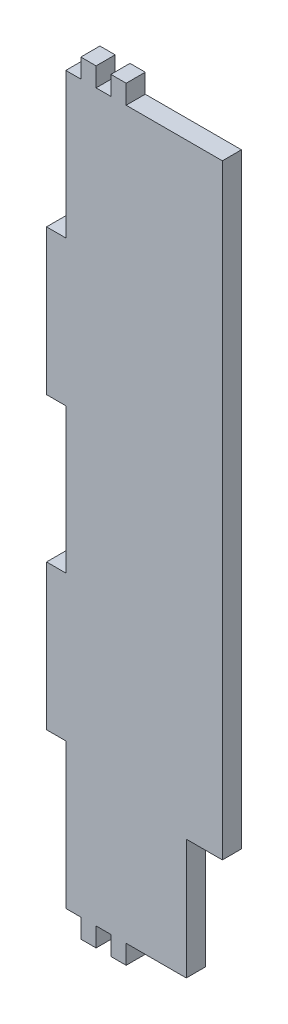
from build123d import *

# Parameters (mm, degrees)
SKETCH1_W           = 5
SKETCH1_H           = 6.35
SKETCH1_W_2         = 25
SKETCH1_H_2         = 241.325
SKETCH1_W_3         = 6.4
SKETCH1_H_3         = 48.265
SKETCH1_W_4         = 15
SKETCH1_W_5         = 12
SKETCH1_H_4         = 201.325
BOSS_EXTRUDE1_DEPTH = 6.35
BOSS_EXTRUDE2_DEPTH = 6.35


with BuildPart() as part:
    # Sketch1 → Boss-Extrude1 (new body)
    with BuildSketch(Plane.XY):
        with Locations((-5, 123.8375)):
            Rectangle(SKETCH1_W, SKETCH1_H)
        with Locations((5, 123.8375)):
            Rectangle(SKETCH1_W, SKETCH1_H)
        Rectangle(SKETCH1_W_2, SKETCH1_H_2)
        with Locations((-15.7, 48.265)):
            Rectangle(SKETCH1_W_3, SKETCH1_H_3)
        with Locations((-15.7, -48.265)):
            Rectangle(SKETCH1_W_3, SKETCH1_H_3)
        with Locations((-5, -123.8375)):
            Rectangle(SKETCH1_W, SKETCH1_H)
        with Locations((5, -123.8375)):
            Rectangle(SKETCH1_W, SKETCH1_H)
        with Locations((20, 0)):
            Rectangle(SKETCH1_W_4, SKETCH1_H_2)
        with Locations((33.5, 20)):
            Rectangle(SKETCH1_W_5, SKETCH1_H_4)
    extrude(amount=BOSS_EXTRUDE1_DEPTH)

    # Sketch2 → Boss-Extrude2 (add)
    with BuildSketch(Plane.XY.offset(6.35)):
        Polygon((27.54064, -120.70314), (27.54064, -80.70314), (39.54064, -80.70314), (39.54064, 120.70314), (7.54064, 120.70314), (7.54064, 127.05314), (2.45936, 127.05314), (2.45936, 120.70314), (-2.45936, 120.70314), (-2.45936, 127.05314), (-7.54064, 127.05314), (-7.54064, 120.70314), (-12.54064, 120.70314), (-12.54064, 72.43814), (-18.94064, 72.43814), (-18.94064, 24.09186), (-12.54064, 24.09186), (-12.54064, -24.09186), (-18.94064, -24.09186), (-18.94064, -72.43814), (-12.54064, -72.43814), (-12.54064, -120.70314), (-7.54064, -120.70314), (-7.54064, -127.05314), (-2.45936, -127.05314), (-2.45936, -120.70314), (2.45936, -120.70314), (2.45936, -127.05314), (7.54064, -127.05314), (7.54064, -120.70314), align=None)
    extrude(amount=-BOSS_EXTRUDE2_DEPTH)


solid = part.part
